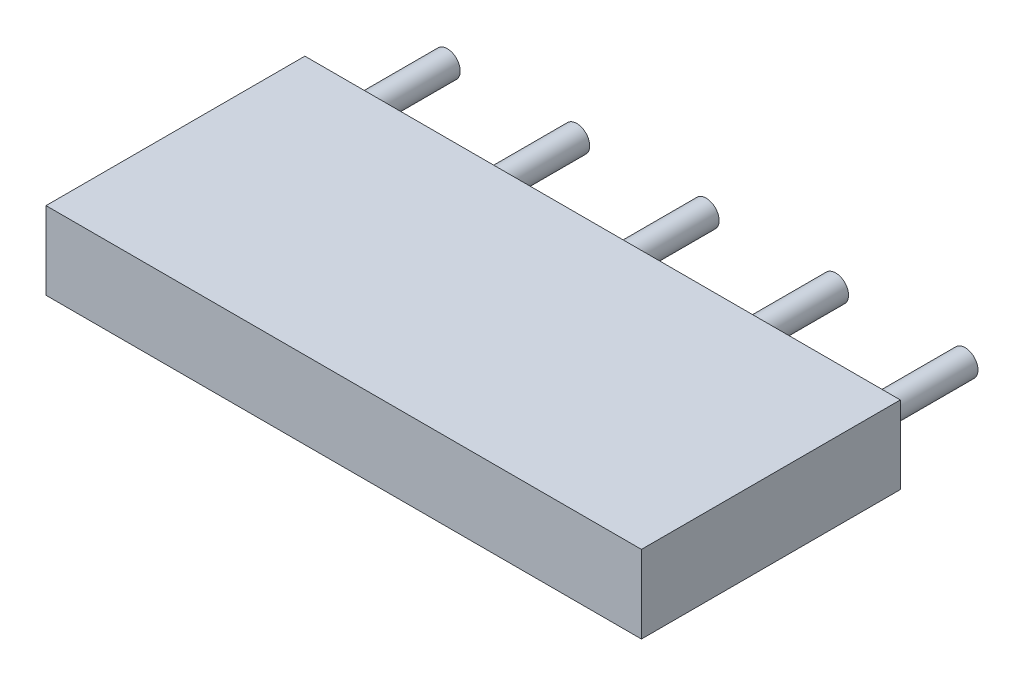
from build123d import *

# Parameters (mm, degrees)
SKETCH1_W               = 11.5
SKETCH1_H               = 1.5
COMPONENT_OUTLINE_DEPTH = 5
SKETCH2_R               = 0.25
EXTRUDE_1_DEPTH         = 2
SKETCH3_R               = 0.25
EXTRUDE_2_DEPTH         = 2
SKETCH4_R               = 0.25
EXTRUDE_3_DEPTH         = 2
SKETCH5_R               = 0.25
EXTRUDE_4_DEPTH         = 2
SKETCH6_R               = 0.25
EXTRUDE_5_DEPTH         = 2


with BuildPart() as part:
    # Sketch1 → Component_Outline (new body)
    with BuildSketch(Plane.XY):
        with Locations((5, 0)):
            Rectangle(SKETCH1_W, SKETCH1_H)
    extrude(amount=COMPONENT_OUTLINE_DEPTH)


with BuildPart() as body_2:
    # Sketch2 → Extrude 1 (new body)
    with BuildSketch(Plane.XY):
        Circle(SKETCH2_R)
    extrude(amount=-EXTRUDE_1_DEPTH)


with BuildPart() as body_3:
    # Sketch3 → Extrude 2 (new body)
    with BuildSketch(Plane.XY):
        with Locations((2.5, 0)):
            Circle(SKETCH3_R)
    extrude(amount=-EXTRUDE_2_DEPTH)


with BuildPart() as body_4:
    # Sketch4 → Extrude 3 (new body)
    with BuildSketch(Plane.XY):
        with Locations((5, 0)):
            Circle(SKETCH4_R)
    extrude(amount=-EXTRUDE_3_DEPTH)


with BuildPart() as body_5:
    # Sketch5 → Extrude 4 (new body)
    with BuildSketch(Plane.XY):
        with Locations((7.5, 0)):
            Circle(SKETCH5_R)
    extrude(amount=-EXTRUDE_4_DEPTH)


with BuildPart() as body_6:
    # Sketch6 → Extrude 5 (new body)
    with BuildSketch(Plane.XY):
        with Locations((10, 0)):
            Circle(SKETCH6_R)
    extrude(amount=-EXTRUDE_5_DEPTH)


solid = Compound([part.part, body_2.part, body_3.part, body_4.part, body_5.part, body_6.part])
